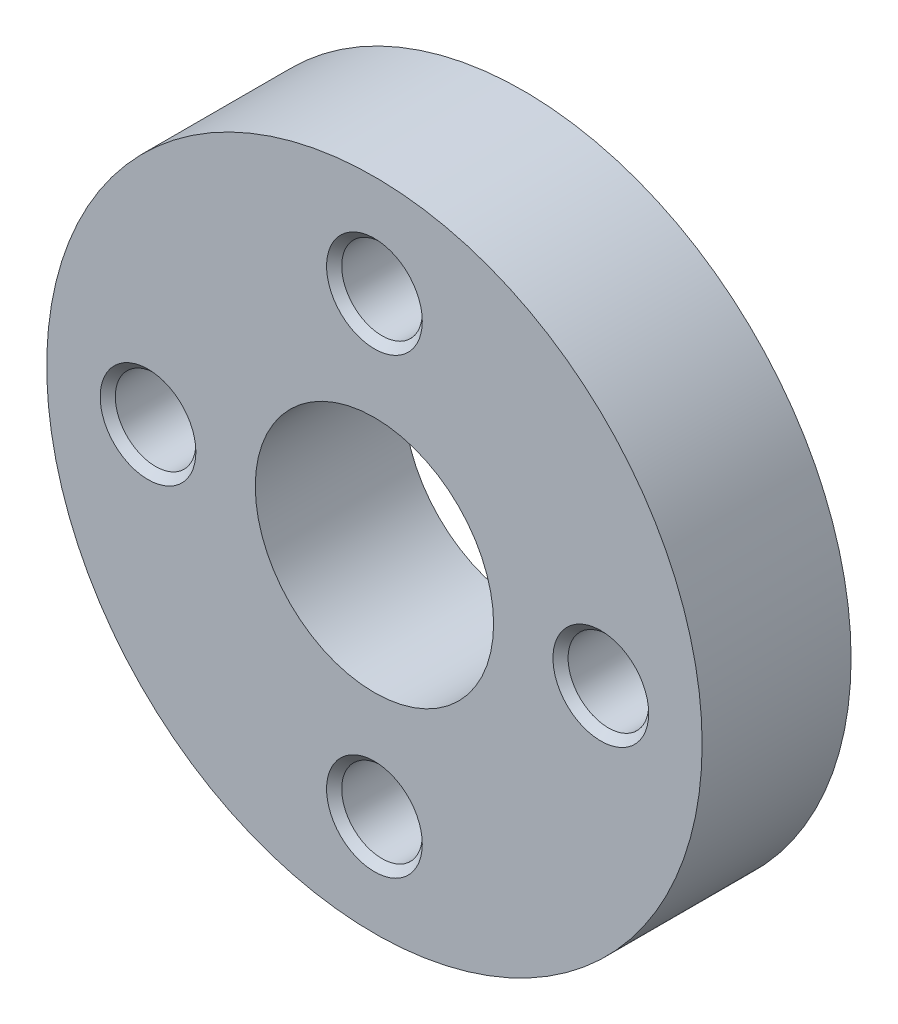
from build123d import *

# Parameters (mm, degrees)
SKETCH1_R             = 11
EXTRUDE1_DEPTH        = 2.5
F_6_32_TAPPED_HOLE3_D = 2.7051
CHAMFER1_SIZE         = 0.254
SKETCH2_R             = 4
EXTRUDE2_DEPTH        = 6


with BuildPart() as part:
    # Sketch1 → Extrude1 (new body, symmetric)
    with BuildSketch(Plane.XY):
        Circle(SKETCH1_R)
    extrude(amount=EXTRUDE1_DEPTH, both=True)

    # #6-32 Tapped Hole3 (through all)
    with Locations(Plane(origin=(0, 7.599342077, 2.5), x_dir=(1, 0, 0), z_dir=(0, 0, 1))):
        with Locations((0, 0), (-7.599342077, -7.599342077), (7.599342077, -7.599342077), (0, -15.198684154)):
            Hole(F_6_32_TAPPED_HOLE3_D / 2)

    # Chamfer1
    chamfer1_edges = [part.edges().sort_by_distance(p)[0] for p in [
        (8.951892077, 0, 2.5),
        (8.951892077, 0, -2.5),
        (-6.246792077, 0, 2.5),
        (-6.246792077, 0, -2.5),
        (1.35255, 7.599342077, 2.5),
        (1.35255, 7.599342077, -2.5),
        (1.35255, -7.599342077, 2.5),
        (1.35255, -7.599342077, -2.5),
    ]]
    chamfer(chamfer1_edges, length=CHAMFER1_SIZE)

    # Sketch2 → Extrude2 (cut, through all)
    with BuildSketch(Plane.XY.offset(2.5)):
        Circle(SKETCH2_R)
    extrude(amount=-EXTRUDE2_DEPTH, mode=Mode.SUBTRACT)


solid = part.part
